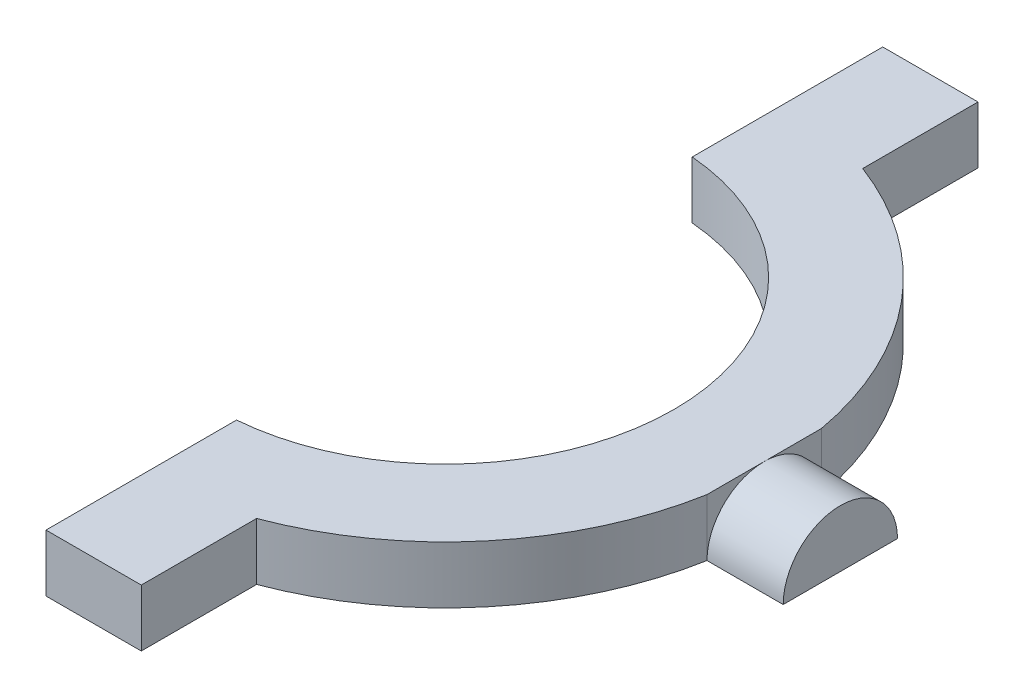
from build123d import *

# Parameters (mm, degrees)
BOSS_EXTRUDE1_DEPTH = 6
SKETCH2_OUTSIDE_W   = 109.13
SKETCH2_OUTSIDE_H   = 27.296
CUT_EXTRUDE1_DEPTH  = 8


with BuildPart() as part:
    # Sketch1 → Boss-Extrude1 (new body)
    with BuildSketch(Plane(origin=(0, 0, 0), x_dir=(1, 0, 0), z_dir=(0, 1, 0))):
        with BuildLine():
            Line((2, 43.916521486), (2, 23.916521486))
            ThreePointArc((2, 23.916521486), (24, 0), (2, -23.916521486))
            Line((2, -23.916521486), (2, -43.916521486))
            Line((2, -43.916521486), (12, -43.916521486))
            Line((12, -43.916521486), (12, -31.811947441))
            ThreePointArc((12, -31.811947441), (26.141204334, -21.740226217), (33.466401061, -6))
            Line((33.466401061, -6), (41.466401061, -6))
            Line((41.466401061, -6), (41.466401061, 6))
            Line((41.466401061, 6), (33.466401061, 6))
            ThreePointArc((33.466401061, 6), (26.141204334, 21.740226217), (12, 31.811947441))
            Line((12, 31.811947441), (12, 43.916521486))
            Line((12, 43.916521486), (2, 43.916521486))
        make_face()
    extrude(amount=BOSS_EXTRUDE1_DEPTH)

    # Sketch2 outside → Cut-Extrude1 (cut)
    with BuildSketch(Plane(origin=(41.466401061, 0, 0), x_dir=(0, 0, -1), z_dir=(1, 0, 0))):
        with Locations((0, 3)):
            Rectangle(SKETCH2_OUTSIDE_W, SKETCH2_OUTSIDE_H)
        with BuildLine():
            Line((-6, 0), (6, 0))
            ThreePointArc((6, 0), (0, 6), (-6, 0))
        make_face(mode=Mode.SUBTRACT)
    extrude(amount=-CUT_EXTRUDE1_DEPTH, mode=Mode.SUBTRACT)


solid = part.part
